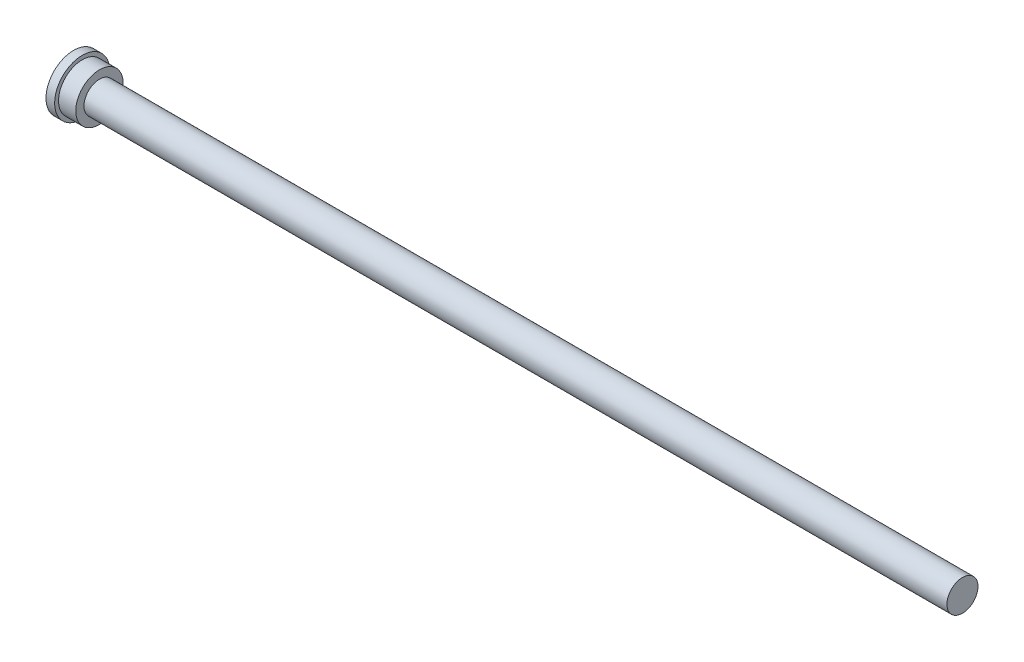
from build123d import *

# Parameters (mm, degrees)
SKETCH1_R           = 34.925
BOSS_EXTRUDE1_DEPTH = 25.4
SKETCH2_R           = 22.86
BOSS_EXTRUDE2_DEPTH = 1270
SKETCH3_R           = 40.64
BOSS_EXTRUDE3_DEPTH = 12.7


with BuildPart() as part:
    # Sketch1 → Boss-Extrude1 (new body)
    with BuildSketch(Plane(origin=(0, 0, 0), x_dir=(0, 0, -1), z_dir=(1, 0, 0))):
        Circle(SKETCH1_R)
    extrude(amount=BOSS_EXTRUDE1_DEPTH)

    # Sketch2 → Boss-Extrude2 (add)
    with BuildSketch(Plane(origin=(25.4, 0, 0), x_dir=(0, 0, -1), z_dir=(1, 0, 0))):
        Circle(SKETCH2_R)
    extrude(amount=BOSS_EXTRUDE2_DEPTH)

    # Sketch3 → Boss-Extrude3 (add)
    with BuildSketch(Plane.ZY):
        Circle(SKETCH3_R)
    extrude(amount=BOSS_EXTRUDE3_DEPTH)


solid = part.part
